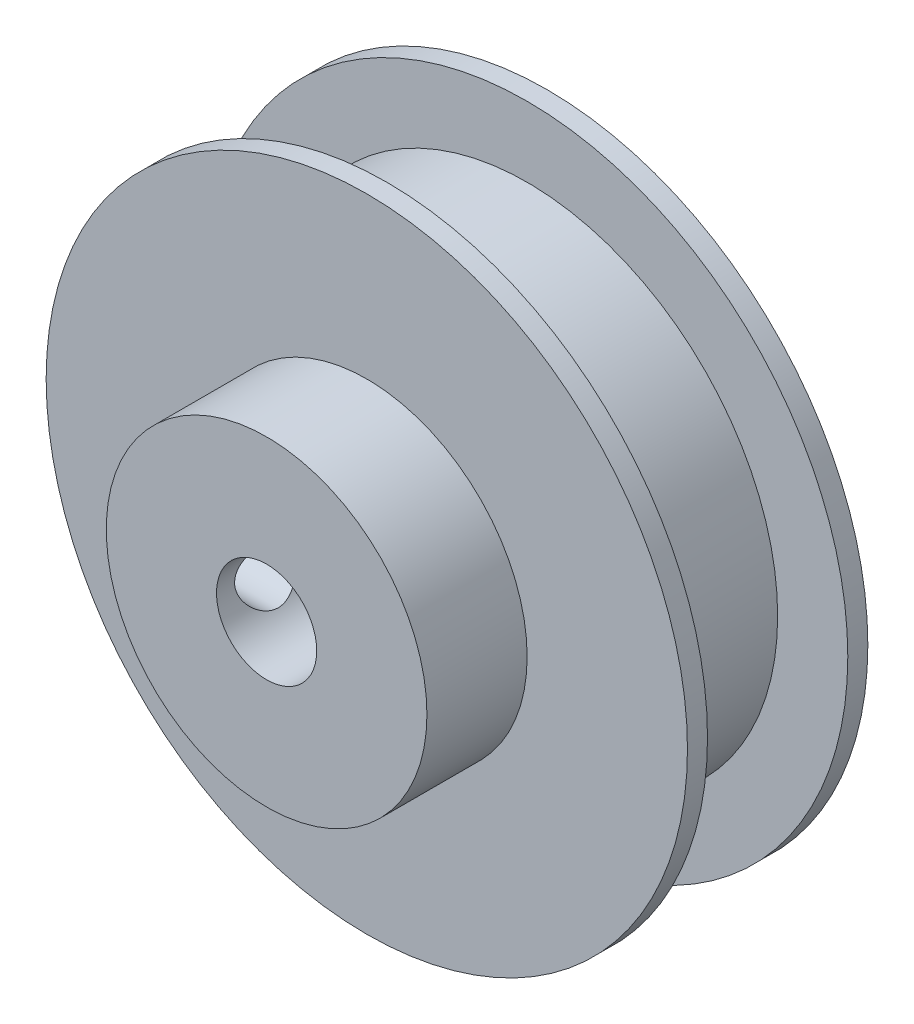
from build123d import *

# Parameters (mm, degrees)
ESQUISSE1_R             = 16
BOSS_EXTRU_1_DEPTH      = 1
ESQUISSE2_R             = 12.5
BOSS_EXTRU_2_DEPTH      = 7
ESQUISSE3_R             = 16
BOSS_EXTRU_3_DEPTH      = 1
ESQUISSE4_R             = 8
BOSS_EXTRU_4_DEPTH      = 5
ESQUISSE5_R             = 2.5
ENL_V_MAT_EXTRU_1_DEPTH = 15


with BuildPart() as part:
    # Esquisse1 → Boss.-Extru.1 (new body)
    with BuildSketch(Plane.XY):
        Circle(ESQUISSE1_R)
    extrude(amount=BOSS_EXTRU_1_DEPTH)

    # Esquisse2 → Boss.-Extru.2 (add)
    with BuildSketch(Plane.XY.offset(1)):
        Circle(ESQUISSE2_R)
    extrude(amount=BOSS_EXTRU_2_DEPTH)

    # Esquisse3 → Boss.-Extru.3 (add)
    with BuildSketch(Plane.XY.offset(8)):
        Circle(ESQUISSE3_R)
    extrude(amount=BOSS_EXTRU_3_DEPTH)

    # Esquisse4 → Boss.-Extru.4 (add)
    with BuildSketch(Plane.XY.offset(9)):
        Circle(ESQUISSE4_R)
    extrude(amount=BOSS_EXTRU_4_DEPTH)

    # Esquisse5 → Enlèv. mat.-Extru.1 (cut, through all)
    with BuildSketch(Plane.XY.offset(14)):
        Circle(ESQUISSE5_R)
    extrude(amount=-ENL_V_MAT_EXTRU_1_DEPTH, mode=Mode.SUBTRACT)

    # Esquisse7 → Dégagement M31 (revolve, cut)
    with BuildSketch(Plane(origin=(-8, 0, 11.497538613), x_dir=(0, 0, 1), z_dir=(0, 1, 0))):
        Polygon((0, 0), (0, 8), (1.6, 8), (1.6, 0.025), (1.625, 0), align=None)
    revolve(axis=Axis((-14.35, 0, 11.497538613), (1, 0, 0)), mode=Mode.SUBTRACT)


solid = part.part
